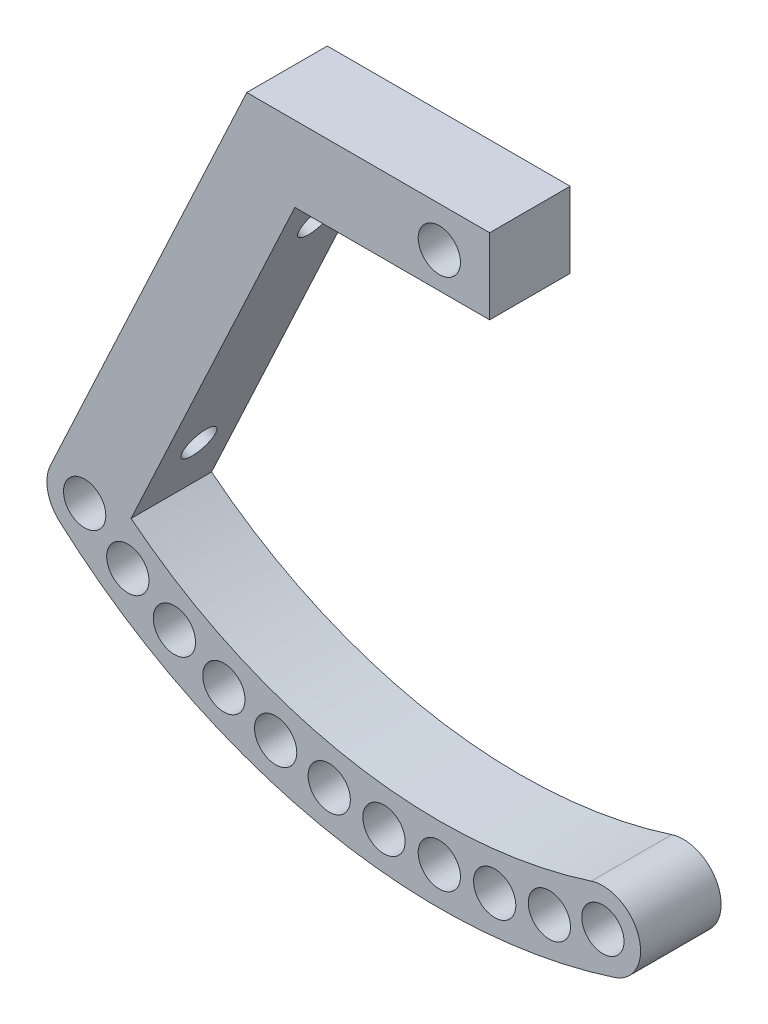
from build123d import *

# Parameters (mm, degrees)
SKETCH1_R           = 2.1
BOSS_EXTRUDE1_DEPTH = 8
CUT_EXTRUDE1_REACH  = 63.082
SKETCH2_R           = 1.65


with BuildPart() as part:
    # Sketch1 → Boss-Extrude1 (new body)
    with BuildSketch(Plane.XY):
        with BuildLine():
            Line((-14.353967242, 72.5), (5, 72.5))
            Line((5, 72.5), (5, 80))
            Line((5, 80), (-19.131994198, 80))
            Line((-19.131994198, 80), (-38.637128513, 38.171104477))
            ThreePointArc((-38.637128513, 38.171104477), (-38.911873787, 35.832206145), (-37.737913805, 33.790699757))
            ThreePointArc((-37.737913805, 33.790699757), (-11.724148086, 20.607586106), (17.400101197, 22.120396774))
            ThreePointArc((17.400101197, 22.120396774), (19.816194151, 26.841360112), (15.095230814, 29.257453067))
            ThreePointArc((15.095230814, 29.257453067), (-8.815701312, 27.678006068), (-30.628506806, 37.599137276))
            Line((-30.628506806, 37.599137276), (-14.353967242, 72.5))
        make_face()
        with Locations((0, 76)):
            Circle(SKETCH1_R, mode=Mode.SUBTRACT)
        with Locations((-30.947084331, 33.134292287)):
            Circle(SKETCH1_R, mode=Mode.SUBTRACT)
        with Locations((-35.238474323, 36.58628597)):
            Circle(SKETCH1_R, mode=Mode.SUBTRACT)
        with Locations((16.247666005, 25.68892492)):
            Circle(SKETCH1_R, mode=Mode.SUBTRACT)
        with Locations((10.932992292, 24.273211913)):
            Circle(SKETCH1_R, mode=Mode.SUBTRACT)
        with Locations((5.5, 23.417294418)):
            Circle(SKETCH1_R, mode=Mode.SUBTRACT)
        with Locations((-26.319869018, 30.147460036)):
            Circle(SKETCH1_R, mode=Mode.SUBTRACT)
        with Locations((-16.261912507, 25.693527972)):
            Circle(SKETCH1_R, mode=Mode.SUBTRACT)
        with Locations((-10.940316211, 24.274760441)):
            Circle(SKETCH1_R, mode=Mode.SUBTRACT)
        with Locations((-21.407041065, 27.658201118)):
            Circle(SKETCH1_R, mode=Mode.SUBTRACT)
        with Locations((-5.5, 23.417294418)):
            Circle(SKETCH1_R, mode=Mode.SUBTRACT)
        with Locations((0, 23.130434783)):
            Circle(SKETCH1_R, mode=Mode.SUBTRACT)
    extrude(amount=BOSS_EXTRUDE1_DEPTH)

    # Sketch2 → Cut-Extrude1 (cut, up to next)
    with BuildSketch(Plane(origin=(-46.356679233, 21.616474533, 0), x_dir=(0, 0, 1), z_dir=(-0.906307787, 0.422618262, 0)), mode=Mode.PRIVATE) as cut_extrude1_sk1:
        with Locations((4, 55.04255297)):
            Circle(SKETCH2_R)
    cut_extrude1_tool1 = extrude(cut_extrude1_sk1.sketch, amount=-CUT_EXTRUDE1_REACH, mode=Mode.PRIVATE) & part.part
    add(cut_extrude1_tool1.solids().sort_by_distance((-23.094691, 71.501969, 4))[0], mode=Mode.SUBTRACT)
    # Sketch2 → Cut-Extrude1 (cut, up to next)
    with BuildSketch(Plane(origin=(-46.356679233, 21.616474533, 0), x_dir=(0, 0, 1), z_dir=(-0.906307787, 0.422618262, 0)), mode=Mode.PRIVATE) as cut_extrude1_sk2:
        with Locations((4, 27.64255297)):
            Circle(SKETCH2_R)
    cut_extrude1_tool2 = extrude(cut_extrude1_sk2.sketch, amount=-CUT_EXTRUDE1_REACH, mode=Mode.PRIVATE) & part.part
    add(cut_extrude1_tool2.solids().sort_by_distance((-34.674432, 46.669136, 4))[0], mode=Mode.SUBTRACT)


solid = part.part
